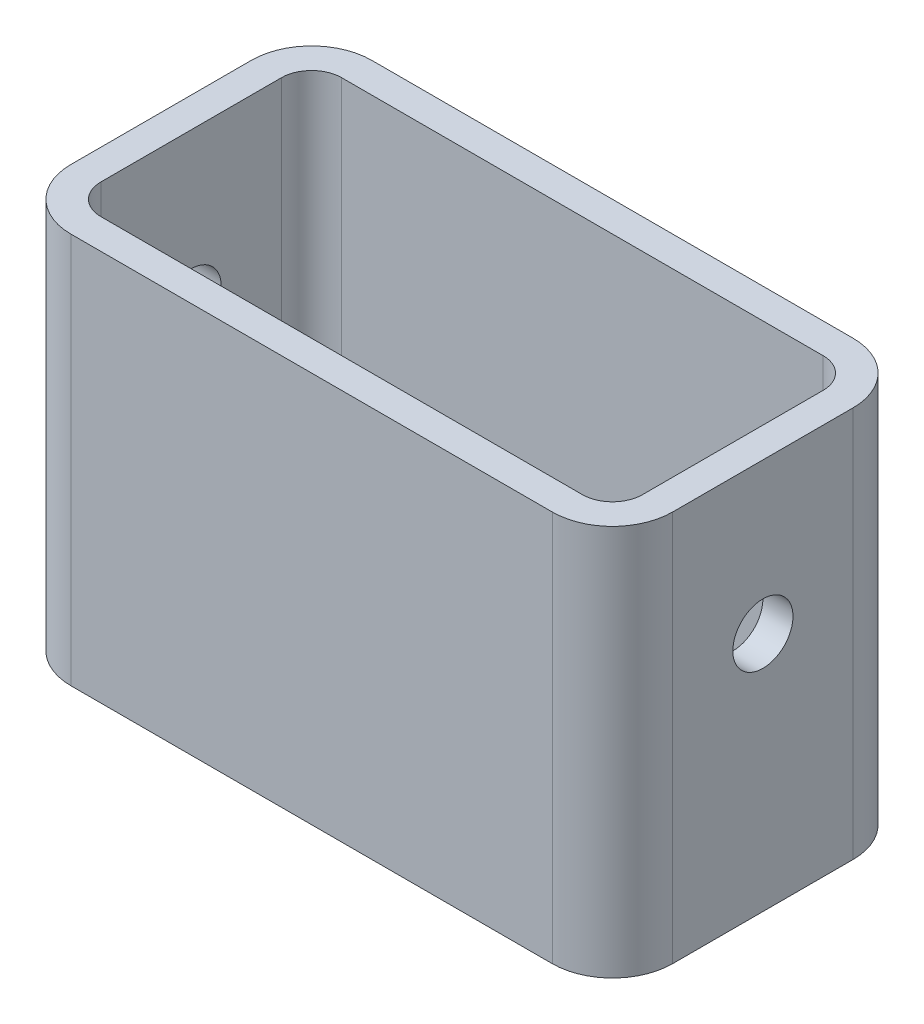
from build123d import *

# Parameters (mm, degrees)
SKETCH2_W           = 100
SKETCH2_H           = 65
BOSS_EXTRUDE1_DEPTH = 50
FILLET1_R           = 10
SHELL1_T            = -5
SKETCH3_R           = 5
CUT_EXTRUDE1_DEPTH  = 101


with BuildPart() as part:
    # Sketch2 → Boss-Extrude1 (new body)
    with BuildSketch(Plane.XY):
        with Locations((50, 32.5)):
            Rectangle(SKETCH2_W, SKETCH2_H)
    extrude(amount=BOSS_EXTRUDE1_DEPTH)

    # Fillet1
    fillet1_edges = [part.edges().sort_by_distance(p)[0] for p in [
        (100, 32.5, 50),
        (0, 32.5, 50),
        (100, 32.5, 0),
        (0, 32.5, 0),
    ]]
    fillet(fillet1_edges, radius=FILLET1_R)

    # Shell1
    shell1_openings = [part.faces().sort_by_distance(p)[0] for p in [
        (50, 65, 25),
    ]]
    offset(amount=SHELL1_T, openings=shell1_openings, kind=Kind.INTERSECTION)

    # Sketch3 → Cut-Extrude1 (cut, through all)
    with BuildSketch(Plane(origin=(100, 0, 0), x_dir=(0, 0, -1), z_dir=(1, 0, 0))):
        with Locations((-25, 40)):
            Circle(SKETCH3_R)
    extrude(amount=-CUT_EXTRUDE1_DEPTH, mode=Mode.SUBTRACT)


solid = part.part
